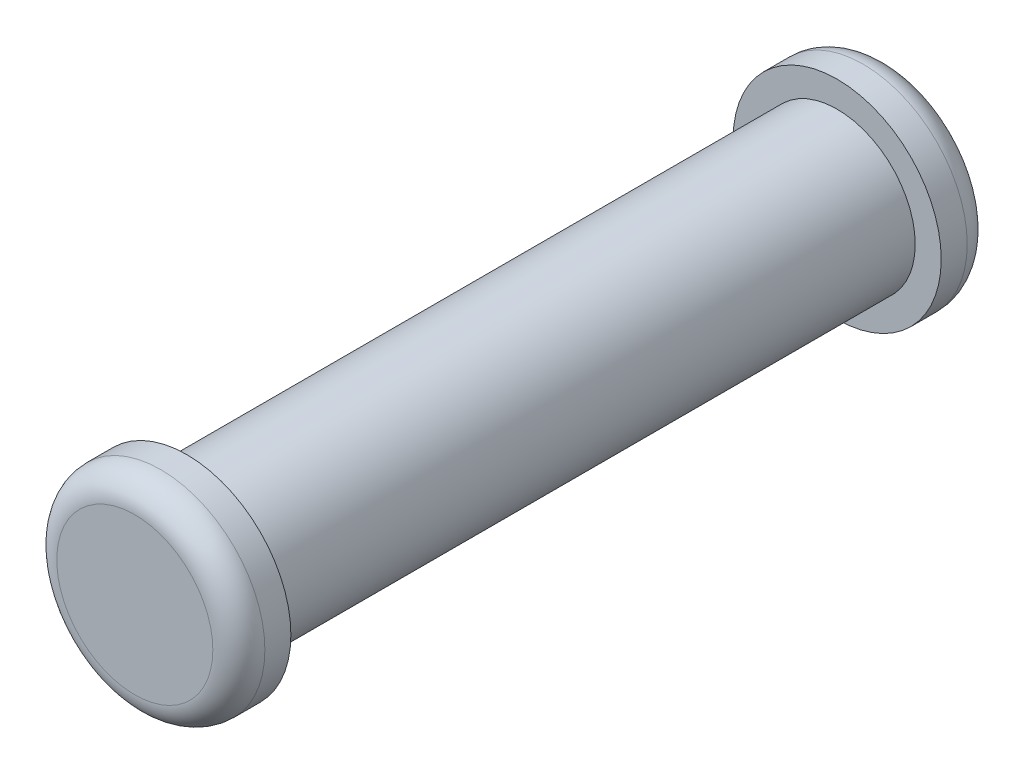
from build123d import *

# Parameters (mm, degrees)
SKETCH1_R           = 1.5
BOSS_EXTRUDE1_DEPTH = 12.5
SKETCH2_R           = 2
BOSS_EXTRUDE2_DEPTH = 1
SKETCH3_R           = 2
BOSS_EXTRUDE3_DEPTH = 1
FILLET1_R           = 0.5


with BuildPart() as part:
    # Sketch1 → Boss-Extrude1 (new body)
    with BuildSketch(Plane.XY):
        Circle(SKETCH1_R)
    extrude(amount=BOSS_EXTRUDE1_DEPTH)

    # Sketch2 → Boss-Extrude2 (add)
    with BuildSketch(Plane(origin=(0, 0, 0), x_dir=(-1, 0, 0), z_dir=(0, 0, -1))):
        Circle(SKETCH2_R)
    extrude(amount=BOSS_EXTRUDE2_DEPTH)

    # Sketch3 → Boss-Extrude3 (add)
    with BuildSketch(Plane.XY.offset(12.5)):
        Circle(SKETCH3_R)
    extrude(amount=BOSS_EXTRUDE3_DEPTH)

    # Fillet1
    fillet1_edges = [part.edges().sort_by_distance(p)[0] for p in [
        (-2, 0, 13.5),
        (2, 0, -1),
    ]]
    fillet(fillet1_edges, radius=FILLET1_R)


solid = part.part
